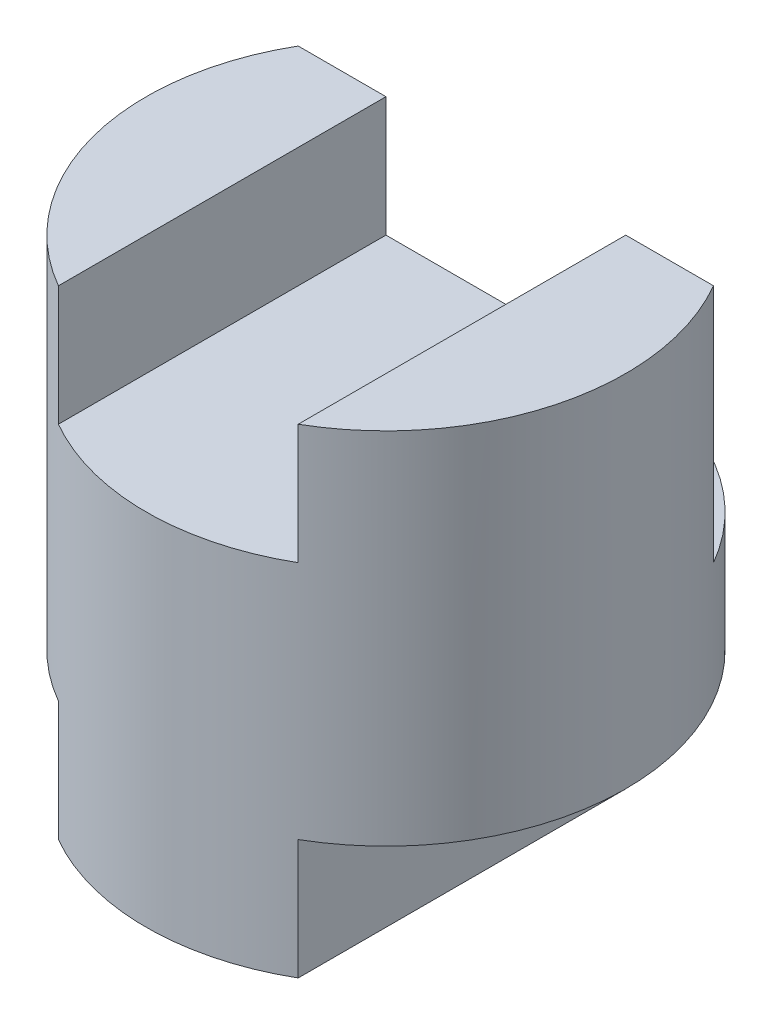
from build123d import *

# Parameters (mm, degrees)
SKETCH1_R           = 2
BOSS_EXTRUDE1_DEPTH = 4
SKETCH2_W           = 1
SKETCH2_H           = 1
SKETCH2_W_2         = 2
CUT_EXTRUDE1_DEPTH  = 5
CUT_EXTRUDE2_DEPTH  = 2
CUT_EXTRUDE3_DEPTH  = 1


with BuildPart() as part:
    # Sketch1 → Boss-Extrude1 (new body)
    with BuildSketch(Plane(origin=(0, 0, 0), x_dir=(1, 0, 0), z_dir=(0, 1, 0))):
        Circle(SKETCH1_R)
    extrude(amount=BOSS_EXTRUDE1_DEPTH)

    # Sketch2 → Cut-Extrude1 (cut, symmetric)
    with BuildSketch(Plane.XY):
        with Locations((-1.5, 0.5)):
            Rectangle(SKETCH2_W, SKETCH2_H)
        with Locations((1.5, 0.5)):
            Rectangle(SKETCH2_W, SKETCH2_H)
        with Locations((0, 3.5)):
            Rectangle(SKETCH2_W_2, SKETCH2_H)
    extrude(amount=CUT_EXTRUDE1_DEPTH, both=True, mode=Mode.SUBTRACT)

    # Sketch3 → Cut-Extrude2 (cut)
    with BuildSketch(Plane(origin=(0, 4, 0), x_dir=(1, 0, 0), z_dir=(0, 1, 0))):
        with BuildLine():
            Line((1.732050808, 1), (-1.732050808, 1))
            ThreePointArc((-1.732050808, 1), (0, 2), (1.732050808, 1))
        make_face()
    extrude(amount=-CUT_EXTRUDE2_DEPTH, mode=Mode.SUBTRACT)

    # Sketch4 → Cut-Extrude3 (cut)
    with BuildSketch(Plane.XZ):
        with BuildLine():
            Line((1.732050808, -1), (-1.732050808, -1))
            ThreePointArc((-1.732050808, -1), (0, -2), (1.732050808, -1))
        make_face()
    extrude(amount=-CUT_EXTRUDE3_DEPTH, mode=Mode.SUBTRACT)


solid = part.part
